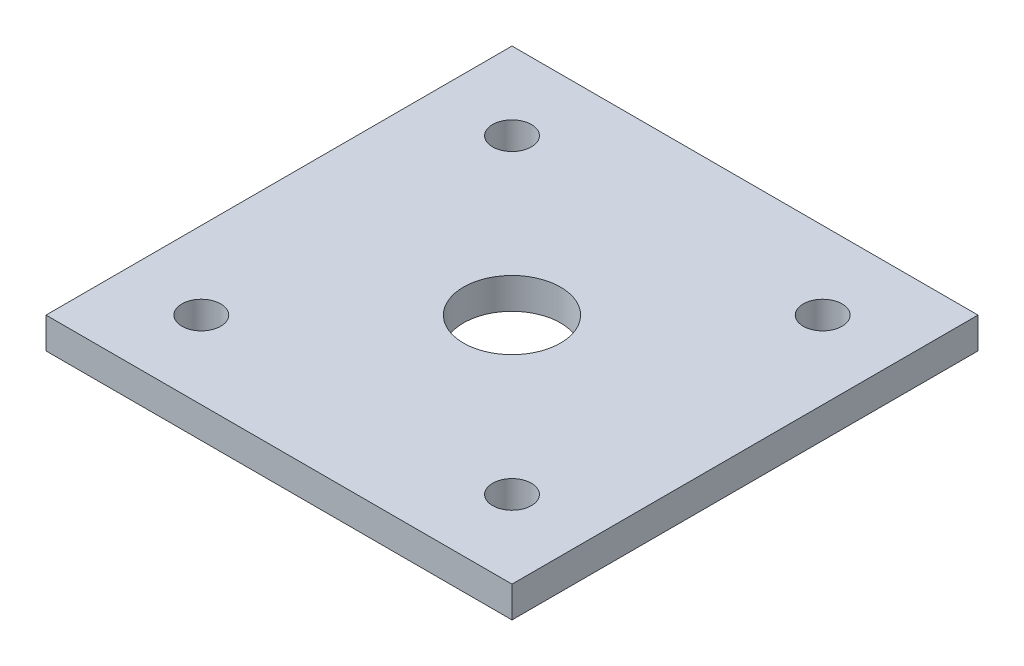
from build123d import *

# Parameters (mm, degrees)
SKETCH1_W           = 120
SKETCH1_H           = 120
BOSS_EXTRUDE2_DEPTH = 8
SKETCH3_R           = 12.5
CUT_EXTRUDE1_DEPTH  = 9
SKETCH4_R           = 5
CUT_EXTRUDE2_DEPTH  = 10


with BuildPart() as part:
    # Sketch1 → Boss-Extrude2 (new body)
    with BuildSketch(Plane(origin=(0, 0, 0), x_dir=(1, 0, 0), z_dir=(0, 1, 0))):
        Rectangle(SKETCH1_W, SKETCH1_H)
    extrude(amount=BOSS_EXTRUDE2_DEPTH)

    # Sketch3 → Cut-Extrude1 (cut, through all)
    with BuildSketch(Plane(origin=(0, 8, 0), x_dir=(1, 0, 0), z_dir=(0, 1, 0))):
        Circle(SKETCH3_R)
    extrude(amount=-CUT_EXTRUDE1_DEPTH, mode=Mode.SUBTRACT)

    # Sketch4 → Cut-Extrude2 (cut)
    with BuildSketch(Plane(origin=(0, 8, 0), x_dir=(1, 0, 0), z_dir=(0, 1, 0))):
        with Locations((-40, 40)):
            Circle(SKETCH4_R)
        with Locations((40, 40)):
            Circle(SKETCH4_R)
        with Locations((40, -40)):
            Circle(SKETCH4_R)
        with Locations((-40, -40)):
            Circle(SKETCH4_R)
    extrude(amount=-CUT_EXTRUDE2_DEPTH, mode=Mode.SUBTRACT)


solid = part.part
